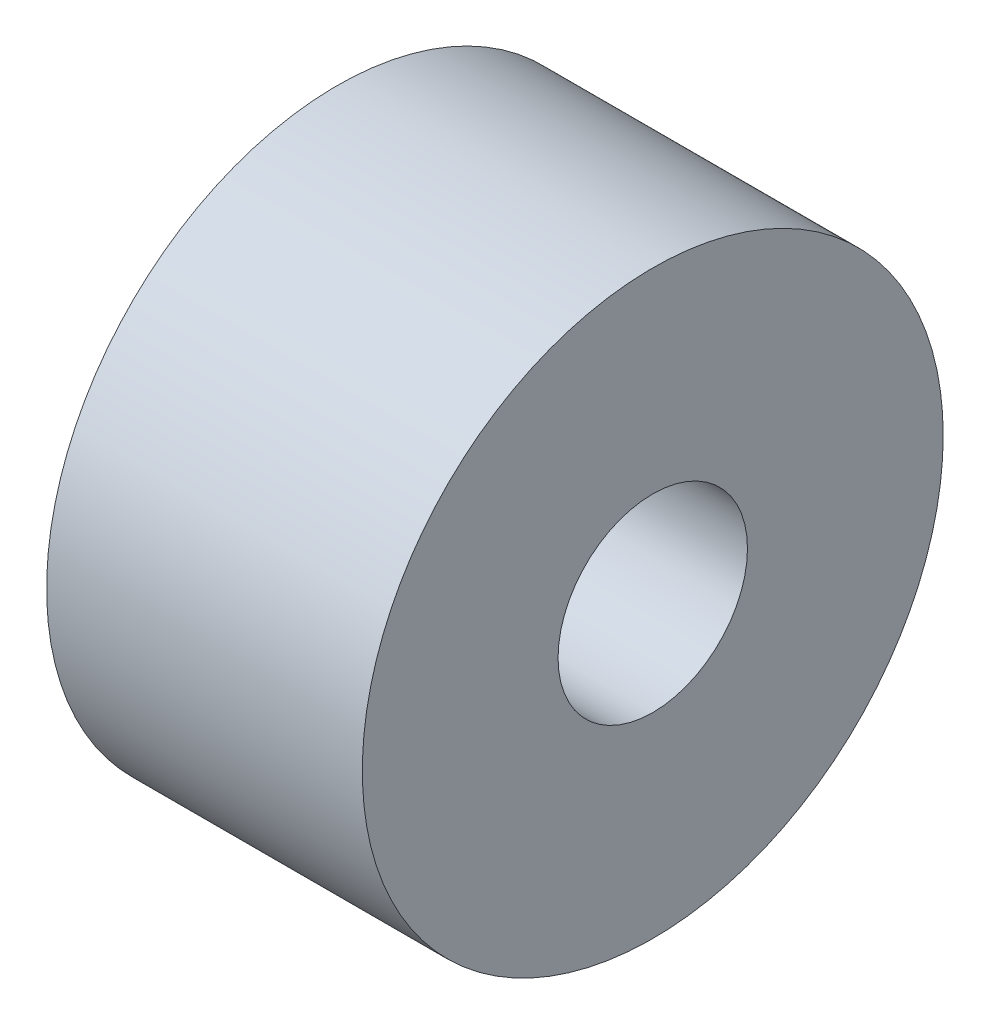
from build123d import *

# Parameters (mm, degrees)
SKETCH1_R           = 4.6
SKETCH1_R_2         = 1.5
BOSS_EXTRUDE1_DEPTH = 5


with BuildPart() as part:
    # Sketch1 → Boss-Extrude1 (new body)
    with BuildSketch(Plane(origin=(0, 0, 0), x_dir=(0, 0, -1), z_dir=(1, 0, 0))):
        Circle(SKETCH1_R)
        Circle(SKETCH1_R_2, mode=Mode.SUBTRACT)
    extrude(amount=BOSS_EXTRUDE1_DEPTH)


solid = part.part
